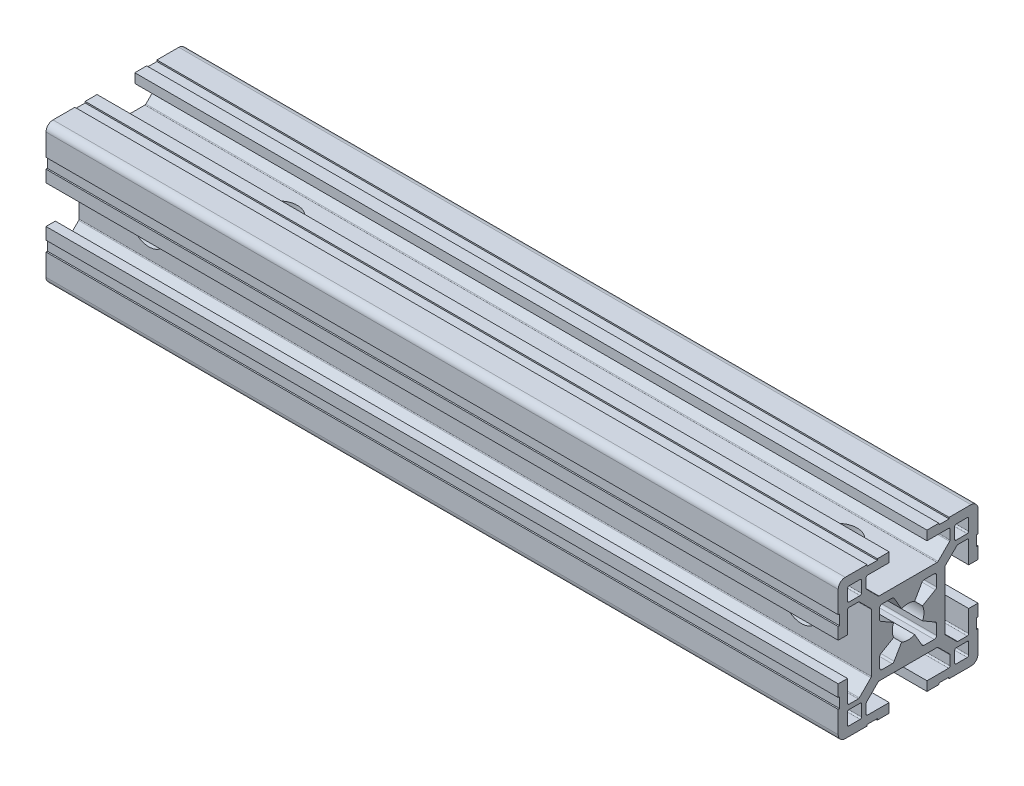
from build123d import *

# Parameters (mm, degrees)
QUADRADO_PF30_11_PERFIL_3030_CENTRO_M8_DEPTH = 170
ESBO_O5_R                                    = 3.9
CORTE_EXTRUS_O3_DEPTH                        = 173.190038711
ESBO_O6_R                                    = 4.0499987
ESBO_O6_R_2                                  = 3.95
CORTE_EXTRUS_O4_DEPTH                        = 173.19003881


with BuildPart() as part:
    # Sketch1 → Quadrado PF30-11 - PERFIL 3030 CENTRO M8(1) (new body)
    with BuildSketch(Plane.YZ):
        with BuildLine():
            Line((14.999995923, 6.599996803), (14.699995923, 6.599996803))
            Line((14.699995923, 6.599996803), (14.699995923, 8.799996803))
            Line((14.699995923, 8.799996803), (14.999995923, 8.799996803))
            Line((14.999995923, 8.799996803), (14.999995923, 13.499995825))
            ThreePointArc((14.999995923, 13.499995825), (14.560656066, 14.560656066), (13.499995825, 14.999995923))
            Line((13.499995825, 14.999995923), (8.799996818, 14.999995923))
            Line((8.799996818, 14.999995923), (8.799996818, 14.699995923))
            Line((8.799996818, 14.699995923), (6.599996818, 14.699995923))
            Line((6.599996818, 14.699995923), (6.599996818, 14.999995923))
            Line((6.599996818, 14.999995923), (4.0499987, 14.999995923))
            Line((4.0499987, 14.999995923), (4.0499987, 12.999995366))
            Line((4.0499987, 12.999995366), (8.699997649, 12.999995366))
            ThreePointArc((8.699997649, 12.999995366), (8.912129683, 12.9121274), (8.999997649, 12.699995366))
            Line((8.999997649, 12.699995366), (8.999997649, 10.679894006))
            ThreePointArc((8.999997649, 10.679894006), (8.977161511, 10.565088981), (8.912129691, 10.467761979))
            Line((8.912129691, 10.467761979), (6.432230191, 7.987862303))
            ThreePointArc((6.432230191, 7.987862303), (6.334903184, 7.922830472), (6.220098149, 7.89999433))
            Line((6.220098149, 7.89999433), (-6.220098149, 7.89999433))
            ThreePointArc((-6.220098149, 7.89999433), (-6.334903184, 7.922830472), (-6.432230191, 7.987862303))
            Line((-6.432230191, 7.987862303), (-8.912129691, 10.467761979))
            ThreePointArc((-8.912129691, 10.467761979), (-8.977161511, 10.565088981), (-8.999997649, 10.679894006))
            Line((-8.999997649, 10.679894006), (-8.999997649, 12.699995366))
            ThreePointArc((-8.999997649, 12.699995366), (-8.912129683, 12.9121274), (-8.699997649, 12.999995366))
            Line((-8.699997649, 12.999995366), (-4.0499987, 12.999995366))
            Line((-4.0499987, 12.999995366), (-4.0499987, 14.999995923))
            Line((-4.0499987, 14.999995923), (-6.599996818, 14.999995923))
            Line((-6.599996818, 14.999995923), (-6.599996818, 14.699995923))
            Line((-6.599996818, 14.699995923), (-8.799996818, 14.699995923))
            Line((-8.799996818, 14.699995923), (-8.799996818, 14.999995923))
            Line((-8.799996818, 14.999995923), (-13.499995825, 14.999995923))
            ThreePointArc((-13.499995825, 14.999995923), (-14.560656066, 14.560656066), (-14.999995923, 13.499995825))
            Line((-14.999995923, 13.499995825), (-14.999995923, 8.799996803))
            Line((-14.999995923, 8.799996803), (-14.699995923, 8.799996803))
            Line((-14.699995923, 8.799996803), (-14.699995923, 6.599996803))
            Line((-14.699995923, 6.599996803), (-14.999995923, 6.599996803))
            Line((-14.999995923, 6.599996803), (-14.999995923, 4.0499987))
            Line((-14.999995923, 4.0499987), (-12.999995366, 4.0499987))
            Line((-12.999995366, 4.0499987), (-12.999995366, 8.699997649))
            ThreePointArc((-12.999995366, 8.699997649), (-12.9121274, 8.912129683), (-12.699995366, 8.999997649))
            Line((-12.699995366, 8.999997649), (-10.679894006, 8.999997649))
            ThreePointArc((-10.679894006, 8.999997649), (-10.565088981, 8.977161511), (-10.467761979, 8.912129691))
            Line((-10.467761979, 8.912129691), (-7.987862303, 6.432230191))
            ThreePointArc((-7.987862303, 6.432230191), (-7.922830472, 6.334903184), (-7.89999433, 6.220098149))
            Line((-7.89999433, 6.220098149), (-7.89999433, -6.220098149))
            ThreePointArc((-7.89999433, -6.220098149), (-7.922830472, -6.334903184), (-7.987862303, -6.432230191))
            Line((-7.987862303, -6.432230191), (-10.467761979, -8.912129691))
            ThreePointArc((-10.467761979, -8.912129691), (-10.565088981, -8.977161511), (-10.679894006, -8.999997649))
            Line((-10.679894006, -8.999997649), (-12.699995366, -8.999997649))
            ThreePointArc((-12.699995366, -8.999997649), (-12.9121274, -8.912129683), (-12.999995366, -8.699997649))
            Line((-12.999995366, -8.699997649), (-12.999995366, -4.0499987))
            Line((-12.999995366, -4.0499987), (-14.999995923, -4.0499987))
            Line((-14.999995923, -4.0499987), (-14.999995923, -6.599996803))
            Line((-14.999995923, -6.599996803), (-14.699995923, -6.599996803))
            Line((-14.699995923, -6.599996803), (-14.699995923, -8.799996803))
            Line((-14.699995923, -8.799996803), (-14.999995923, -8.799996803))
            Line((-14.999995923, -8.799996803), (-14.999995923, -13.499995825))
            ThreePointArc((-14.999995923, -13.499995825), (-14.560656066, -14.560656066), (-13.499995825, -14.999995923))
            Line((-13.499995825, -14.999995923), (-8.799996818, -14.999995923))
            Line((-8.799996818, -14.999995923), (-8.799996818, -14.699995923))
            Line((-8.799996818, -14.699995923), (-6.599996818, -14.699995923))
            Line((-6.599996818, -14.699995923), (-6.599996818, -14.999995923))
            Line((-6.599996818, -14.999995923), (-4.0499987, -14.999995923))
            Line((-4.0499987, -14.999995923), (-4.0499987, -12.999995366))
            Line((-4.0499987, -12.999995366), (-8.699997649, -12.999995366))
            ThreePointArc((-8.699997649, -12.999995366), (-8.912129683, -12.9121274), (-8.999997649, -12.699995366))
            Line((-8.999997649, -12.699995366), (-8.999997649, -10.679894006))
            ThreePointArc((-8.999997649, -10.679894006), (-8.977161511, -10.565088981), (-8.912129691, -10.467761979))
            Line((-8.912129691, -10.467761979), (-6.432230191, -7.987862303))
            ThreePointArc((-6.432230191, -7.987862303), (-6.334903184, -7.922830472), (-6.220098149, -7.89999433))
            Line((-6.220098149, -7.89999433), (6.220098149, -7.89999433))
            ThreePointArc((6.220098149, -7.89999433), (6.334903184, -7.922830472), (6.432230191, -7.987862303))
            Line((6.432230191, -7.987862303), (8.912129691, -10.467761979))
            ThreePointArc((8.912129691, -10.467761979), (8.977161511, -10.565088981), (8.999997649, -10.679894006))
            Line((8.999997649, -10.679894006), (8.999997649, -12.699995366))
            ThreePointArc((8.999997649, -12.699995366), (8.912129683, -12.9121274), (8.699997649, -12.999995366))
            Line((8.699997649, -12.999995366), (4.0499987, -12.999995366))
            Line((4.0499987, -12.999995366), (4.0499987, -14.999995923))
            Line((4.0499987, -14.999995923), (6.599996818, -14.999995923))
            Line((6.599996818, -14.999995923), (6.599996818, -14.699995923))
            Line((6.599996818, -14.699995923), (8.799996818, -14.699995923))
            Line((8.799996818, -14.699995923), (8.799996818, -14.999995923))
            Line((8.799996818, -14.999995923), (13.499995825, -14.999995923))
            ThreePointArc((13.499995825, -14.999995923), (14.560656066, -14.560656066), (14.999995923, -13.499995825))
            Line((14.999995923, -13.499995825), (14.999995923, -8.799996803))
            Line((14.999995923, -8.799996803), (14.699995923, -8.799996803))
            Line((14.699995923, -8.799996803), (14.699995923, -6.599996803))
            Line((14.699995923, -6.599996803), (14.999995923, -6.599996803))
            Line((14.999995923, -6.599996803), (14.999995923, -4.0499987))
            Line((14.999995923, -4.0499987), (12.999995366, -4.0499987))
            Line((12.999995366, -4.0499987), (12.999995366, -8.699997649))
            ThreePointArc((12.999995366, -8.699997649), (12.9121274, -8.912129683), (12.699995366, -8.999997649))
            Line((12.699995366, -8.999997649), (10.679894006, -8.999997649))
            ThreePointArc((10.679894006, -8.999997649), (10.565088981, -8.977161511), (10.467761979, -8.912129691))
            Line((10.467761979, -8.912129691), (7.987862303, -6.432230191))
            ThreePointArc((7.987862303, -6.432230191), (7.922830472, -6.334903184), (7.89999433, -6.220098149))
            Line((7.89999433, -6.220098149), (7.89999433, 6.220098149))
            ThreePointArc((7.89999433, 6.220098149), (7.922830472, 6.334903184), (7.987862303, 6.432230191))
            Line((7.987862303, 6.432230191), (10.467761979, 8.912129691))
            ThreePointArc((10.467761979, 8.912129691), (10.565088981, 8.977161511), (10.679894006, 8.999997649))
            Line((10.679894006, 8.999997649), (12.699995366, 8.999997649))
            ThreePointArc((12.699995366, 8.999997649), (12.9121274, 8.912129683), (12.999995366, 8.699997649))
            Line((12.999995366, 8.699997649), (12.999995366, 4.0499987))
            Line((12.999995366, 4.0499987), (14.999995923, 4.0499987))
            Line((14.999995923, 4.0499987), (14.999995923, 6.599996803))
        make_face()
        with BuildLine():
            Line((-6.1, -3.425408784), (-6.1, -5.6))
            ThreePointArc((-6.1, -5.6), (-5.953553391, -5.953553391), (-5.6, -6.1))
            Line((-5.6, -6.1), (-3.425408784, -6.1))
            ThreePointArc((-3.425408784, -6.1), (-3.175408784, -6.033012702), (-2.992396082, -5.85))
            Line((-2.992396082, -5.85), (-1.402974441, -3.097040962))
            ThreePointArc((-1.402974441, -3.097040962), (0, -3.4), (1.402974441, -3.097040962))
            Line((1.402974441, -3.097040962), (2.992396082, -5.85))
            ThreePointArc((2.992396082, -5.85), (3.175408784, -6.033012702), (3.425408784, -6.1))
            Line((3.425408784, -6.1), (5.6, -6.1))
            ThreePointArc((5.6, -6.1), (5.953553391, -5.953553391), (6.1, -5.6))
            Line((6.1, -5.6), (6.1, -3.425408784))
            ThreePointArc((6.1, -3.425408784), (6.033012702, -3.175408784), (5.85, -2.992396082))
            Line((5.85, -2.992396082), (3.097040962, -1.402974441))
            ThreePointArc((3.097040962, -1.402974441), (3.4, 0), (3.097040962, 1.402974441))
            Line((3.097040962, 1.402974441), (5.85, 2.992396082))
            ThreePointArc((5.85, 2.992396082), (6.033012702, 3.175408784), (6.1, 3.425408784))
            Line((6.1, 3.425408784), (6.1, 5.6))
            ThreePointArc((6.1, 5.6), (5.953553391, 5.953553391), (5.6, 6.1))
            Line((5.6, 6.1), (3.425408784, 6.1))
            ThreePointArc((3.425408784, 6.1), (3.175408784, 6.033012702), (2.992396082, 5.85))
            Line((2.992396082, 5.85), (1.402974441, 3.097040962))
            ThreePointArc((1.402974441, 3.097040962), (0, 3.4), (-1.402974441, 3.097040962))
            Line((-1.402974441, 3.097040962), (-2.992396082, 5.85))
            ThreePointArc((-2.992396082, 5.85), (-3.175408784, 6.033012702), (-3.425408784, 6.1))
            Line((-3.425408784, 6.1), (-5.6, 6.1))
            ThreePointArc((-5.6, 6.1), (-5.953553391, 5.953553391), (-6.1, 5.6))
            Line((-6.1, 5.6), (-6.1, 3.425408784))
            ThreePointArc((-6.1, 3.425408784), (-6.033012702, 3.175408784), (-5.85, 2.992396082))
            Line((-5.85, 2.992396082), (-3.097040962, 1.402974441))
            ThreePointArc((-3.097040962, 1.402974441), (-3.4, 0), (-3.097040962, -1.402974441))
            Line((-3.097040962, -1.402974441), (-5.85, -2.992396082))
            ThreePointArc((-5.85, -2.992396082), (-6.033012702, -3.175408784), (-6.1, -3.425408784))
        make_face(mode=Mode.SUBTRACT)
        with BuildLine():
            Line((9.999995366, 12.699997649), (9.999995366, 10.299997649))
            ThreePointArc((9.999995366, 10.299997649), (10.087863331, 10.087865615), (10.299995366, 9.999997649))
            Line((10.299995366, 9.999997649), (12.699995366, 9.999997649))
            ThreePointArc((12.699995366, 9.999997649), (12.9121274, 10.087865615), (12.999995366, 10.299997649))
            Line((12.999995366, 10.299997649), (12.999995366, 12.699997649))
            ThreePointArc((12.999995366, 12.699997649), (12.9121274, 12.912129683), (12.699995366, 12.999997649))
            Line((12.699995366, 12.999997649), (10.299995366, 12.999997649))
            ThreePointArc((10.299995366, 12.999997649), (10.087863331, 12.912129683), (9.999995366, 12.699997649))
        make_face(mode=Mode.SUBTRACT)
        with BuildLine():
            Line((12.999995366, -12.699997649), (12.999995366, -10.299997649))
            ThreePointArc((12.999995366, -10.299997649), (12.9121274, -10.087865615), (12.699995366, -9.999997649))
            Line((12.699995366, -9.999997649), (10.299995366, -9.999997649))
            ThreePointArc((10.299995366, -9.999997649), (10.087863331, -10.087865615), (9.999995366, -10.299997649))
            Line((9.999995366, -10.299997649), (9.999995366, -12.699997649))
            ThreePointArc((9.999995366, -12.699997649), (10.087863331, -12.912129683), (10.299995366, -12.999997649))
            Line((10.299995366, -12.999997649), (12.699995366, -12.999997649))
            ThreePointArc((12.699995366, -12.999997649), (12.9121274, -12.912129683), (12.999995366, -12.699997649))
        make_face(mode=Mode.SUBTRACT)
        with BuildLine():
            Line((-10.299995366, -9.999997649), (-12.699995366, -9.999997649))
            ThreePointArc((-12.699995366, -9.999997649), (-12.9121274, -10.087865615), (-12.999995366, -10.299997649))
            Line((-12.999995366, -10.299997649), (-12.999995366, -12.699997649))
            ThreePointArc((-12.999995366, -12.699997649), (-12.9121274, -12.912129683), (-12.699995366, -12.999997649))
            Line((-12.699995366, -12.999997649), (-10.299995366, -12.999997649))
            ThreePointArc((-10.299995366, -12.999997649), (-10.087863331, -12.912129683), (-9.999995366, -12.699997649))
            Line((-9.999995366, -12.699997649), (-9.999995366, -10.299997649))
            ThreePointArc((-9.999995366, -10.299997649), (-10.087863331, -10.087865615), (-10.299995366, -9.999997649))
        make_face(mode=Mode.SUBTRACT)
        with BuildLine():
            Line((-12.999995366, 12.699997649), (-12.999995366, 10.299997649))
            ThreePointArc((-12.999995366, 10.299997649), (-12.9121274, 10.087865615), (-12.699995366, 9.999997649))
            Line((-12.699995366, 9.999997649), (-10.299995366, 9.999997649))
            ThreePointArc((-10.299995366, 9.999997649), (-10.087863331, 10.087865615), (-9.999995366, 10.299997649))
            Line((-9.999995366, 10.299997649), (-9.999995366, 12.699997649))
            ThreePointArc((-9.999995366, 12.699997649), (-10.087863331, 12.912129683), (-10.299995366, 12.999997649))
            Line((-10.299995366, 12.999997649), (-12.699995366, 12.999997649))
            ThreePointArc((-12.699995366, 12.999997649), (-12.9121274, 12.912129683), (-12.999995366, 12.699997649))
        make_face(mode=Mode.SUBTRACT)
    extrude(amount=QUADRADO_PF30_11_PERFIL_3030_CENTRO_M8_DEPTH)

    # Esboço5 → Corte-extrusão3 (cut, through all)
    with BuildSketch(Plane.XY.offset(7.89999433)):
        with Locations(Location((15, 0, 0), (0, 0, 21.084047391))):
            Circle(ESBO_O5_R)
        with Locations(Location((155.000004077, 0, 0), (0, 0, 21.084047391))):
            Circle(ESBO_O5_R)
    extrude(amount=-CORTE_EXTRUS_O3_DEPTH, mode=Mode.SUBTRACT)

    # Esboço6 → Corte-extrusão4 (cut, through all)
    with BuildSketch(Plane.XZ.offset(7.89999433)):
        with Locations(Location((155, 0, 0), (0, 0, 270))):
            Circle(ESBO_O6_R)
        with Locations(Location((35, 0, 0), (0, 0, 270))):
            Circle(ESBO_O6_R_2)
    extrude(amount=-CORTE_EXTRUS_O4_DEPTH, mode=Mode.SUBTRACT)


solid = part.part
